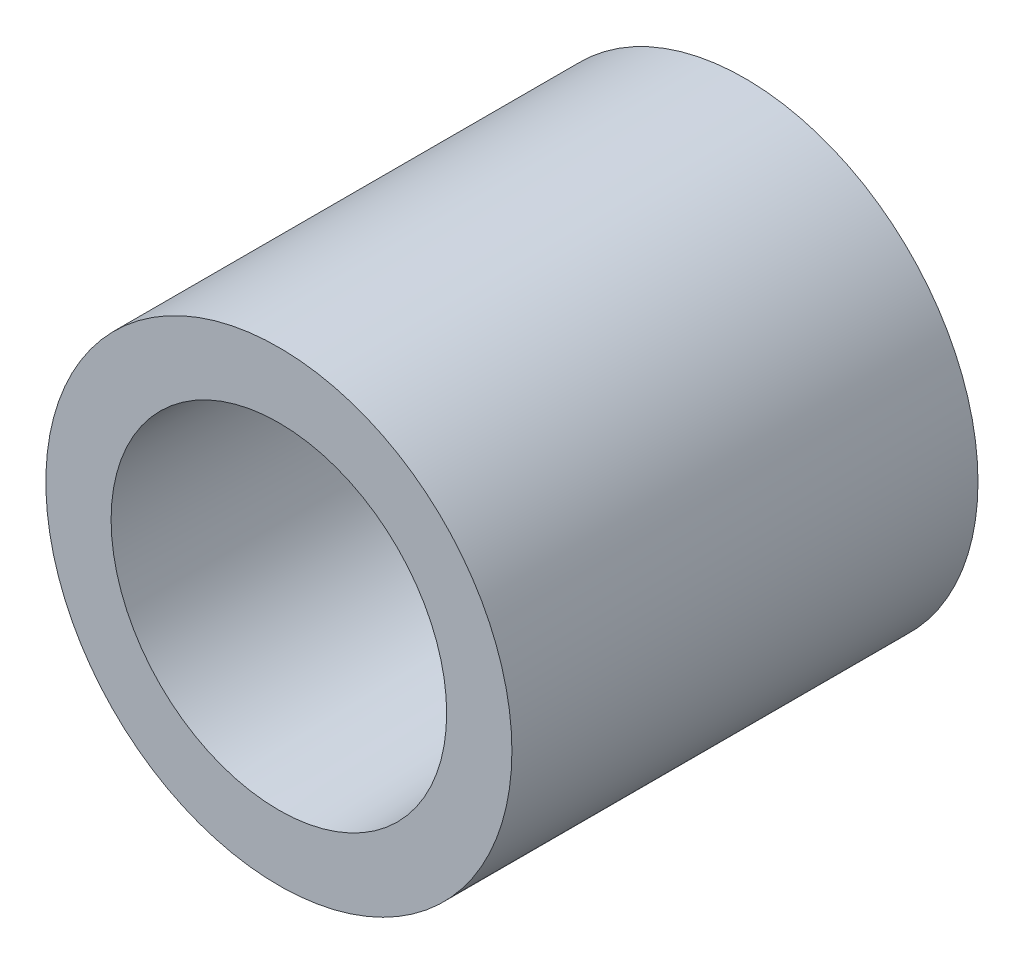
from build123d import *

# Parameters (mm, degrees)
SKETCH1_R                                        = 9.525
BOSS_EXTRUDE1_DEPTH                              = 19.05
CBORE_FOR_1_4_SOCKET_HEAD_CAP_SCREW1_D           = 0.79375
CBORE_FOR_1_4_SOCKET_HEAD_CAP_SCREW1_DEPTH       = 12.7
CBORE_FOR_1_4_SOCKET_HEAD_CAP_SCREW1_CBORE_D     = 3.175
CBORE_FOR_1_4_SOCKET_HEAD_CAP_SCREW1_CBORE_DEPTH = 3.175
CBORE_FOR_1_4_SOCKET_HEAD_CAP_SCREW1_TIP         = 0.238466558


with BuildPart() as part:
    # Sketch1 → Boss-Extrude1 (new body)
    with BuildSketch(Plane.XY):
        Circle(SKETCH1_R)
    extrude(amount=BOSS_EXTRUDE1_DEPTH)

    # Sketch6 → 1/4 NPT Tapped Hole1 (revolve, cut)
    with BuildSketch(Plane(origin=(0, 0, 19.05), x_dir=(0, -1, 0), z_dir=(1, 0, 0))):
        Polygon((0, 0), (0, 14.772347279), (5.5626, 11.43), (5.5626, 10.0203), (6.557978799, 10.0203), (6.858, 0), align=None)
    revolve(axis=Axis((0, 0, 25.4), (0, 0, -1)), mode=Mode.SUBTRACT)

    # CBORE for 1/4 Socket Head Cap Screw1
    with Locations(Plane(origin=(0, 0, 0), x_dir=(-1, 0, 0), z_dir=(0, 0, -1))):
        with Locations((0, 0)):
            CounterBoreHole(CBORE_FOR_1_4_SOCKET_HEAD_CAP_SCREW1_D / 2, CBORE_FOR_1_4_SOCKET_HEAD_CAP_SCREW1_CBORE_D / 2, CBORE_FOR_1_4_SOCKET_HEAD_CAP_SCREW1_CBORE_DEPTH, depth=CBORE_FOR_1_4_SOCKET_HEAD_CAP_SCREW1_DEPTH)
            with Locations((0, 0, -(CBORE_FOR_1_4_SOCKET_HEAD_CAP_SCREW1_DEPTH + CBORE_FOR_1_4_SOCKET_HEAD_CAP_SCREW1_TIP / 2))):  # 118° drill point
                Cone(0, CBORE_FOR_1_4_SOCKET_HEAD_CAP_SCREW1_D / 2, CBORE_FOR_1_4_SOCKET_HEAD_CAP_SCREW1_TIP, mode=Mode.SUBTRACT)


solid = part.part
